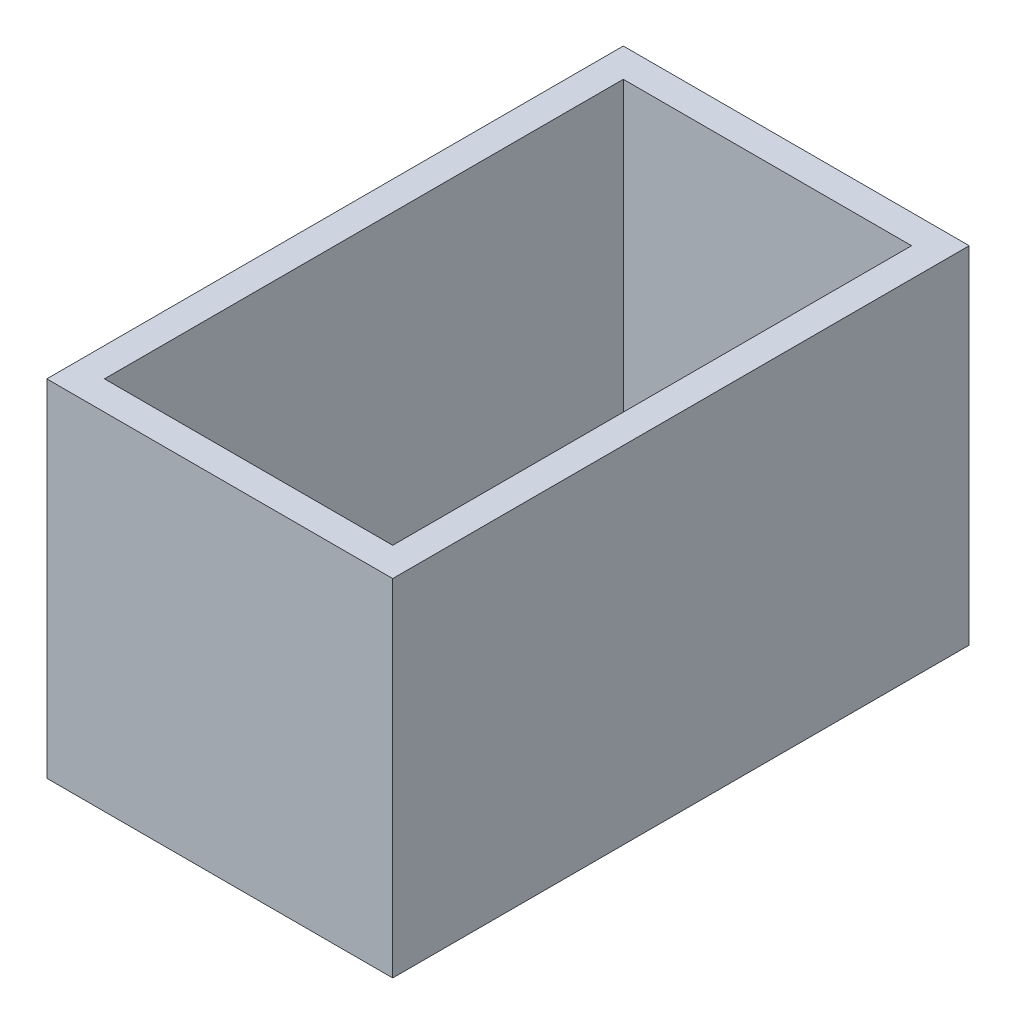
from build123d import *

# Parameters (mm, degrees)
SKETCH1_W           = 76.2
SKETCH1_H           = 127
BOSS_EXTRUDE1_DEPTH = 76.2
SHELL1_T            = -6.35


with BuildPart() as part:
    # Sketch1 → Boss-Extrude1 (new body)
    with BuildSketch(Plane(origin=(0, 0, 0), x_dir=(1, 0, 0), z_dir=(0, 1, 0))):
        with Locations((38.1, 63.5)):
            Rectangle(SKETCH1_W, SKETCH1_H)
    extrude(amount=BOSS_EXTRUDE1_DEPTH)

    # Shell1
    shell1_openings = [part.faces().sort_by_distance(p)[0] for p in [
        (38.1, 76.2, -63.5),
    ]]
    offset(amount=SHELL1_T, openings=shell1_openings, kind=Kind.INTERSECTION)


solid = part.part
